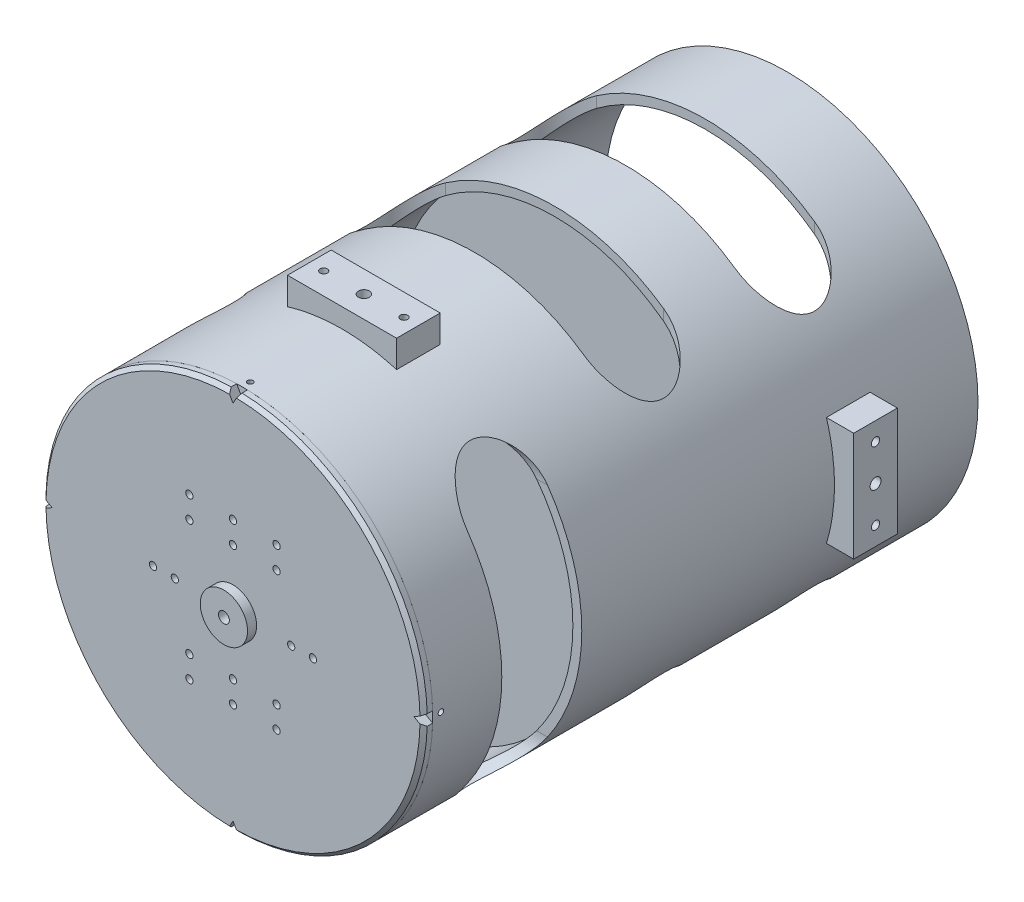
from build123d import *

# Parameters (mm, degrees)
ESQUISSE1_R                  = 104.9
ESQUISSE1_R_2                = 100
BOSS_EXTRU_1_DEPTH           = 300
ESQUISSE2_R                  = 100
BOSS_EXTRU_2_DEPTH           = 24
ESQUISSE3_R                  = 13
ENL_V_MAT_EXTRU_1_DEPTH      = 8
ESQUISSE5_R                  = 5
ENL_V_MAT_EXTRU_2_DEPTH      = 16
ESQUISSE6_R                  = 99.5
ESQUISSE6_R_2                = 95
BOSS_EXTRU_3_DEPTH           = 8
ESQUISSE7_R                  = 104.9
ESQUISSE7_R_2                = 3
BOSS_EXTRU_4_DEPTH           = 5
CHANFREIN1_SIZE              = 2
ESQUISSE8_R                  = 13
ESQUISSE8_R_2                = 3
BOSS_EXTRU_5_DEPTH           = 5
ENL_V_MAT_EXTRU_3_DEPTH      = 177.5
ESQUISSE10_R                 = 3
ENL_V_MAT_EXTRU_4_DEPTH      = 355
ENL_V_MAT_EXTRU_5_DEPTH      = 177.5
ESQUISSE12_W                 = 24
ESQUISSE12_H                 = 96
BOSS_EXTRU_6_DEPTH           = 12
ESQUISSE13_R                 = 2.25
ENL_V_MAT_EXTRU_6_DEPTH      = 25
ESQUISSE14_R                 = 2
ENL_V_MAT_EXTRU_7_DEPTH      = 25
ESQUISSE15_R                 = 3
ENL_V_MAT_EXTRU_8_DEPTH      = 147.5
ESQUISSE16_W                 = 96
ESQUISSE16_H                 = 24
BOSS_EXTRU_7_DEPTH           = 12
ESQUISSE17_R                 = 2.25
ENL_V_MAT_EXTRU_9_DEPTH      = 25
BOSS_EXTRU_8_DEPTH           = 12
BOSS_EXTRU_8_2_DEPTH         = 12
BOSS_EXTRU_9_DEPTH           = 12
BOSS_EXTRU_9_2_DEPTH         = 12
BOSS_EXTRU_10_DEPTH          = 12
ESQUISSE22_R                 = 2
ENL_V_MAT_EXTRU_10_DEPTH     = 17
SYM_TRIE7_COPY_1_SKETCH_R    = 2
SYM_TRIE7_COPY_1_DEPTH       = 17
ENL_V_MAT_EXTRU_11_REACH     = 222.419
ESQUISSE24_R                 = 3
BOSS_EXTRU_11_DEPTH          = 12
ESQUISSE27_R                 = 2.25
ENL_V_MAT_EXTRU_12_DEPTH     = 17
ESQUISSE28_R                 = 3
ENL_V_MAT_EXTRU_13_DEPTH     = 34
ESQUISSE29_R                 = 1.5
ENL_V_MAT_EXTRU_14_DEPTH     = 14
R_P_TITION_CIRCULAIRE1_COUNT = 4
ESQUISSE31_R                 = 2
ENL_V_MAT_EXTRU_15_DEPTH     = 5
ENL_V_MAT_EXTRU_16_DEPTH     = 14
ESQUISSE33_W                 = 6
ESQUISSE33_H                 = 24
BOSS_EXTRU_12_DEPTH          = 47
BOSS_EXTRU_12_2_DEPTH        = 47
BOSS_EXTRU_12_3_DEPTH        = 47
BOSS_EXTRU_12_4_DEPTH        = 47


with BuildPart() as part:
    # Esquisse1 → Boss.-Extru.1 (new body)
    with BuildSketch(Plane.XY):
        Circle(ESQUISSE1_R)
        Circle(ESQUISSE1_R_2, mode=Mode.SUBTRACT)
    extrude(amount=BOSS_EXTRU_1_DEPTH)

    # Esquisse9 → Enl_v. mat.-Extru.3 (cut, symmetric)
    with BuildSketch(Plane(origin=(0, 0, 0), x_dir=(1, 0, 0), z_dir=(0, 1, 0))):
        with BuildLine():
            Line((-60, -128), (60, -128))
            ThreePointArc((60, -128), (82, -150), (60, -172))
            Line((60, -172), (-60, -172))
            ThreePointArc((-60, -172), (-82, -150), (-60, -128))
        make_face()
    enl_v_mat_extru_3 = extrude(amount=ENL_V_MAT_EXTRU_3_DEPTH, both=True, mode=Mode.SUBTRACT)

    # Esquisse10 → Enl_v. mat.-Extru.4 (cut)
    with BuildSketch(Plane(origin=(0, -104.9, 0), x_dir=(1, 0, 0), z_dir=(0, 1, 0))):
        with Locations(Location((0, -233, 0), (0, 0, 90))):  # turned: the seam where the file's is
            Circle(ESQUISSE10_R)
    extrude(amount=ENL_V_MAT_EXTRU_4_DEPTH, mode=Mode.SUBTRACT)

    # Esquisse11 → Enl_v. mat.-Extru.5 (cut, symmetric)
    with BuildSketch(Plane.ZY):
        with BuildLine():
            Line((218, -60), (218, 60))
            ThreePointArc((218, 60), (240, 82), (262, 60))
            Line((262, 60), (262, -60))
            ThreePointArc((262, -60), (240, -82), (218, -60))
        make_face()
    extrude(amount=ENL_V_MAT_EXTRU_5_DEPTH, both=True, mode=Mode.SUBTRACT)

    # Esquisse15 → Enl_v. mat.-Extru.8 (cut, symmetric)
    with BuildSketch(Plane.ZY):
        with Locations((67, 0)):
            Circle(ESQUISSE15_R)
    extrude(amount=ENL_V_MAT_EXTRU_8_DEPTH, both=True, mode=Mode.SUBTRACT)

    # Sym_trie3: Enl_v. mat.-Extru.3 across plane
    add(enl_v_mat_extru_3.mirror(Plane.XY.offset(108.5)), mode=Mode.SUBTRACT)


with BuildPart() as body_2:
    # Esquisse2 → Boss.-Extru.2 (new body)
    with BuildSketch(Plane.XY.offset(210)):
        Circle(ESQUISSE2_R)
    extrude(amount=-BOSS_EXTRU_2_DEPTH)

    # Esquisse3 → Enl_v. mat.-Extru.1 (cut)
    with BuildSketch(Plane.XY.offset(210)):
        Circle(ESQUISSE3_R)
    extrude(amount=-ENL_V_MAT_EXTRU_1_DEPTH, mode=Mode.SUBTRACT)

    # Esquisse5 → Enl_v. mat.-Extru.2 (cut)
    with BuildSketch(Plane.XY.offset(202)):
        Circle(ESQUISSE5_R)
    extrude(amount=-ENL_V_MAT_EXTRU_2_DEPTH, mode=Mode.SUBTRACT)


with BuildPart() as body_3:
    # Sym_trie1: mirrored copy
    add(body_2.part.mirror(Plane.XY.offset(150)))


with BuildPart() as body_4:
    # Esquisse6 → Boss.-Extru.3 (new body)
    with BuildSketch(Plane.XY.offset(300)):
        Circle(ESQUISSE6_R)
        Circle(ESQUISSE6_R_2, mode=Mode.SUBTRACT)
    extrude(amount=-BOSS_EXTRU_3_DEPTH)

    # Esquisse7 → Boss.-Extru.4 (add)
    with BuildSketch(Plane.XY.offset(300)):
        Circle(ESQUISSE7_R)
        Circle(ESQUISSE7_R_2, mode=Mode.SUBTRACT)
    extrude(amount=BOSS_EXTRU_4_DEPTH)

    # Chanfrein1
    chanfrein1_edges = [body_4.edges().sort_by_distance(p)[0] for p in [
        (-104.9, 0, 305),
    ]]
    chamfer(chanfrein1_edges, length=CHANFREIN1_SIZE)

    # Esquisse14 → Enl_v. mat.-Extru.7 (cut)
    with BuildSketch(Plane.XY.offset(305)):
        with Locations((0, 32)):
            Circle(ESQUISSE14_R)
        with Locations((0, -32)):
            Circle(ESQUISSE14_R)
        with Locations((32, 0)):
            Circle(ESQUISSE14_R)
        with Locations((-32, 0)):
            Circle(ESQUISSE14_R)
        with Locations((0, 44)):
            Circle(ESQUISSE14_R)
        with Locations((44, 0)):
            Circle(ESQUISSE14_R)
        with Locations((0, -44)):
            Circle(ESQUISSE14_R)
        with Locations((-44, 0)):
            Circle(ESQUISSE14_R)
    extrude(amount=-ENL_V_MAT_EXTRU_7_DEPTH, mode=Mode.SUBTRACT)


with BuildPart() as body_5:
    # Esquisse8 → Boss.-Extru.5 (new body)
    with BuildSketch(Plane.XY.offset(305)):
        Circle(ESQUISSE8_R)
        Circle(ESQUISSE8_R_2, mode=Mode.SUBTRACT)
    extrude(amount=BOSS_EXTRU_5_DEPTH)


with BuildPart() as body_6:
    # Esquisse12 → Boss.-Extru.6 (new body, symmetric)
    with BuildSketch(Plane.XY.offset(233)):
        Rectangle(ESQUISSE12_W, ESQUISSE12_H)
    extrude(amount=BOSS_EXTRU_6_DEPTH, both=True)

    # Esquisse13 → Enl_v. mat.-Extru.6 (cut)
    with BuildSketch(Plane(origin=(0, 48, 0), x_dir=(0, 0, -1), z_dir=(0, 1, 0))):
        with Locations(Location((-233, 0, 0), (0, 0, 90))):  # turned: the seam where the file's is
            Circle(ESQUISSE13_R)
    enl_v_mat_extru_6 = extrude(amount=-ENL_V_MAT_EXTRU_6_DEPTH, mode=Mode.SUBTRACT)

    # Sym_trie2: Enl_v. mat.-Extru.6 across plane
    add(enl_v_mat_extru_6.mirror(Plane.ZX), mode=Mode.SUBTRACT)


with BuildPart() as body_7:
    # Esquisse16 → Boss.-Extru.7 (new body, symmetric)
    with BuildSketch(Plane.XY.offset(67)):
        Rectangle(ESQUISSE16_W, ESQUISSE16_H)
    extrude(amount=BOSS_EXTRU_7_DEPTH, both=True)

    # Esquisse17 → Enl_v. mat.-Extru.9 (cut)
    with BuildSketch(Plane.YZ.offset(48)):
        with Locations((0, 67)):
            Circle(ESQUISSE17_R)
    enl_v_mat_extru_9 = extrude(amount=-ENL_V_MAT_EXTRU_9_DEPTH, mode=Mode.SUBTRACT)

    # Sym_trie4: Enl_v. mat.-Extru.9 across plane
    add(enl_v_mat_extru_9.mirror(Plane.ZY), mode=Mode.SUBTRACT)


with BuildPart() as body_8:
    # Esquisse18 → Boss.-Extru.8 (new body, symmetric)
    with BuildSketch(Plane.XY.offset(233)):
        with BuildLine():
            Line((-12.5, 99.215674165), (-12.5, 84.215674165))
            Line((-12.5, 84.215674165), (12.5, 84.215674165))
            Line((12.5, 84.215674165), (12.5, 99.215674165))
            ThreePointArc((12.5, 99.215674165), (0, 100), (-12.5, 99.215674165))
        make_face()
    extrude(amount=BOSS_EXTRU_8_DEPTH, both=True)


with BuildPart() as body_9:
    # Esquisse18 → Boss.-Extru.8 2 (new body, symmetric)
    with BuildSketch(Plane.XY.offset(233)):
        with BuildLine():
            Line((12.5, -84.215674165), (12.5, -99.215674165))
            ThreePointArc((12.5, -99.215674165), (0, -100), (-12.5, -99.215674165))
            Line((-12.5, -99.215674165), (-12.5, -84.215674165))
            Line((-12.5, -84.215674165), (12.5, -84.215674165))
        make_face()
    extrude(amount=BOSS_EXTRU_8_2_DEPTH, both=True)


with BuildPart() as body_10:
    # Esquisse19 → Boss.-Extru.9 (new body, symmetric)
    with BuildSketch(Plane.XY.offset(67)):
        with BuildLine():
            Line((99.215674165, 12.5), (84.215674165, 12.5))
            Line((84.215674165, 12.5), (84.215674165, -12.5))
            Line((84.215674165, -12.5), (99.215674165, -12.5))
            ThreePointArc((99.215674165, -12.5), (100, 0), (99.215674165, 12.5))
        make_face()
    extrude(amount=BOSS_EXTRU_9_DEPTH, both=True)


with BuildPart() as body_11:
    # Esquisse19 → Boss.-Extru.9 2 (new body, symmetric)
    with BuildSketch(Plane.XY.offset(67)):
        with BuildLine():
            Line((-99.215674165, -12.5), (-84.215674165, -12.5))
            Line((-84.215674165, -12.5), (-84.215674165, 12.5))
            Line((-84.215674165, 12.5), (-99.215674165, 12.5))
            ThreePointArc((-99.215674165, 12.5), (-100, 0), (-99.215674165, -12.5))
        make_face()
    extrude(amount=BOSS_EXTRU_9_2_DEPTH, both=True)


with BuildPart() as body_12:
    # Esquisse21 → Boss.-Extru.10 (new body, symmetric)
    with BuildSketch(Plane.XY.offset(233)):
        with BuildLine():
            Line((-30, 100.518704727), (-30, 115.518704727))
            Line((-30, 115.518704727), (30, 115.518704727))
            Line((30, 115.518704727), (30, 100.518704727))
            ThreePointArc((30, 100.518704727), (0, 104.9), (-30, 100.518704727))
        make_face()
    extrude(amount=BOSS_EXTRU_10_DEPTH, both=True)


with BuildPart() as enl_v_mat_extru_10_tool:
    # Esquisse22 → Enl_v. mat.-Extru.10 (new body, symmetric)
    with BuildSketch(Plane(origin=(-15, 102.709352364, 0), x_dir=(0.98950331, 0.144510206, 0), z_dir=(-0.144510206, 0.98950331, 0))):
        with Locations((-5.15912059, -233)):
            Circle(ESQUISSE22_R)
    enl_v_mat_extru_10 = extrude(amount=ENL_V_MAT_EXTRU_10_DEPTH, both=True)


with BuildPart() as part_1:
    add(part.part)

    # Enl_v. mat.-Extru.10: cut by enl_v_mat_extru_10_tool
    add(enl_v_mat_extru_10_tool.part, mode=Mode.SUBTRACT)


with BuildPart() as body_12_1:
    add(body_12.part)

    # Enl_v. mat.-Extru.10: cut by enl_v_mat_extru_10_tool
    add(enl_v_mat_extru_10_tool.part, mode=Mode.SUBTRACT)


with BuildPart() as sym_trie5_tool:
    # Sym_trie5: Enl_v. mat.-Extru.10 across plane
    add(enl_v_mat_extru_10.mirror(Plane.ZY))


with BuildPart() as part_2:
    add(part_1.part)

    # Sym_trie5: cut by sym_trie5_tool
    add(sym_trie5_tool.part, mode=Mode.SUBTRACT)

    # Sym_trie7: Enl_v. mat.-Extru.10 across plane
    add(enl_v_mat_extru_10.mirror(Plane.ZX), mode=Mode.SUBTRACT)

    # Sym_trie7 copy 1 sketch → Sym_trie7 copy 1 (cut, symmetric)
    with BuildSketch(Plane(origin=(15, -102.709352364, 0), x_dir=(-0.98950331, -0.144510206, 0), z_dir=(0.144510206, -0.98950331, 0))):
        with Locations((-5.15912059, -233)):
            Circle(SYM_TRIE7_COPY_1_SKETCH_R)
    extrude(amount=SYM_TRIE7_COPY_1_DEPTH, both=True, mode=Mode.SUBTRACT)


with BuildPart() as body_12_2:
    add(body_12_1.part)

    # Sym_trie5: cut by sym_trie5_tool
    add(sym_trie5_tool.part, mode=Mode.SUBTRACT)

    # Esquisse24 → Enl_v. mat.-Extru.11 (cut, up to next)
    with BuildSketch(Plane(origin=(0, 115.518704727, 0), x_dir=(1, 0, 0), z_dir=(0, 1, 0)), mode=Mode.PRIVATE) as enl_v_mat_extru_11_sk1:
        with Locations(Location((0, -233, 0), (0, 0, 270))):  # turned: the seam where the file's is
            Circle(ESQUISSE24_R)
    enl_v_mat_extru_11_tool1 = extrude(enl_v_mat_extru_11_sk1.sketch, amount=-ENL_V_MAT_EXTRU_11_REACH, mode=Mode.PRIVATE) & body_12_2.part
    add(enl_v_mat_extru_11_tool1.solids().sort_by_distance((0, 115.518705, 233))[0], mode=Mode.SUBTRACT)


with BuildPart() as body_13:
    # Sym_trie10: mirrored copy
    add(body_12_2.part.mirror(Plane.ZX))


with BuildPart() as body_14:
    # Esquisse25 → Boss.-Extru.11 (new body, symmetric)
    with BuildSketch(Plane.XY.offset(67)):
        with BuildLine():
            Line((100.518704727, -30), (115.518704727, -30))
            Line((115.518704727, -30), (115.518704727, 30))
            Line((115.518704727, 30), (100.518704727, 30))
            ThreePointArc((100.518704727, 30), (104.9, 0), (100.518704727, -30))
        make_face()
    extrude(amount=BOSS_EXTRU_11_DEPTH, both=True)


with BuildPart() as enl_v_mat_extru_12_tool:
    # Esquisse27 → Enl_v. mat.-Extru.12 (new body, symmetric)
    with BuildSketch(Plane(origin=(102.709352364, 15, 0), x_dir=(0, 0, -1), z_dir=(0.98950331, 0.144510206, 0))):
        with Locations(Location((-67, 2.991467503, 0), (0, 0, 90))):  # turned: the seam where the file's is
            Circle(ESQUISSE27_R)
    enl_v_mat_extru_12 = extrude(amount=ENL_V_MAT_EXTRU_12_DEPTH, both=True)


with BuildPart() as part_3:
    add(part_2.part)

    # Enl_v. mat.-Extru.12: cut by enl_v_mat_extru_12_tool
    add(enl_v_mat_extru_12_tool.part, mode=Mode.SUBTRACT)


with BuildPart() as body_14_1:
    add(body_14.part)

    # Enl_v. mat.-Extru.12: cut by enl_v_mat_extru_12_tool
    add(enl_v_mat_extru_12_tool.part, mode=Mode.SUBTRACT)


with BuildPart() as sym_trie11_tool:
    # Sym_trie11: Enl_v. mat.-Extru.12 across plane
    add(enl_v_mat_extru_12.mirror(Plane.ZX))


with BuildPart() as part_4:
    add(part_3.part)

    # Sym_trie11: cut by sym_trie11_tool
    add(sym_trie11_tool.part, mode=Mode.SUBTRACT)


with BuildPart() as body_14_2:
    add(body_14_1.part)

    # Sym_trie11: cut by sym_trie11_tool
    add(sym_trie11_tool.part, mode=Mode.SUBTRACT)


with BuildPart() as enl_v_mat_extru_13_tool:
    # Esquisse28 → Enl_v. mat.-Extru.13 (new body)
    with BuildSketch(Plane(origin=(115.518704727, 0, 0), x_dir=(0, 0, -1), z_dir=(1, 0, 0))):
        with Locations(Location((-67, 0, 0), (0, 0, 90))):  # turned: the seam where the file's is
            Circle(ESQUISSE28_R)
    extrude(amount=-ENL_V_MAT_EXTRU_13_DEPTH)


with BuildPart() as body_10_1:
    add(body_10.part)

    # Enl_v. mat.-Extru.13: cut by enl_v_mat_extru_13_tool
    add(enl_v_mat_extru_13_tool.part, mode=Mode.SUBTRACT)


with BuildPart() as body_14_3:
    add(body_14_2.part)

    # Enl_v. mat.-Extru.13: cut by enl_v_mat_extru_13_tool
    add(enl_v_mat_extru_13_tool.part, mode=Mode.SUBTRACT)


with BuildPart() as body_15:
    # Sym_trie12: mirrored copy
    add(body_14_3.part.mirror(Plane.ZY))


with BuildPart() as enl_v_mat_extru_14_tool:
    # Esquisse29 → Enl_v. mat.-Extru.14 (new body)
    with BuildSketch(Plane(origin=(0, 104.9, 0), x_dir=(1, 0, 0), z_dir=(0, 1, 0))):
        with Locations(Location((0, -295.5, 0), (0, 0, 270))):  # turned: the seam where the file's is
            Circle(ESQUISSE29_R)
    enl_v_mat_extru_14 = extrude(amount=-ENL_V_MAT_EXTRU_14_DEPTH)


with BuildPart() as part_5:
    add(part_4.part)

    # Enl_v. mat.-Extru.14: cut by enl_v_mat_extru_14_tool
    add(enl_v_mat_extru_14_tool.part, mode=Mode.SUBTRACT)


with BuildPart() as body_4_1:
    add(body_4.part)

    # Enl_v. mat.-Extru.14: cut by enl_v_mat_extru_14_tool
    add(enl_v_mat_extru_14_tool.part, mode=Mode.SUBTRACT)


with BuildPart() as r_p_tition_circulaire1_tool:
    # R_p_tition circulaire1: Enl_v. mat.-Extru.14 ×4 about axis
    r_p_tition_circulaire1_axis = Axis((0, 0, 0), (0, 0, 1))
    for i in range(1, R_P_TITION_CIRCULAIRE1_COUNT):
        add(enl_v_mat_extru_14.rotate(r_p_tition_circulaire1_axis, i * 360 / R_P_TITION_CIRCULAIRE1_COUNT))


with BuildPart() as part_6:
    add(part_5.part)

    # R_p_tition circulaire1: cut by r_p_tition_circulaire1_tool
    add(r_p_tition_circulaire1_tool.part, mode=Mode.SUBTRACT)


with BuildPart() as body_4_2:
    add(body_4_1.part)

    # R_p_tition circulaire1: cut by r_p_tition_circulaire1_tool
    add(r_p_tition_circulaire1_tool.part, mode=Mode.SUBTRACT)

    # Esquisse31 → Enl_v. mat.-Extru.15 (cut)
    with BuildSketch(Plane(origin=(0, 0, 300), x_dir=(-1, 0, 0), z_dir=(0, 0, -1))):
        with Locations((-24, 44)):
            Circle(ESQUISSE31_R)
        with Locations((-24, 32)):
            Circle(ESQUISSE31_R)
        with Locations((24, 44)):
            Circle(ESQUISSE31_R)
        with Locations((24, 32)):
            Circle(ESQUISSE31_R)
        with Locations(Location((24, -32, 0), (0, 0, 180))):  # turned: the seam where the file's is
            Circle(ESQUISSE31_R)
        with Locations(Location((24, -44, 0), (0, 0, 180))):  # turned: the seam where the file's is
            Circle(ESQUISSE31_R)
        with Locations(Location((-24, -32, 0), (0, 0, 180))):  # turned: the seam where the file's is
            Circle(ESQUISSE31_R)
        with Locations(Location((-24, -44, 0), (0, 0, 180))):  # turned: the seam where the file's is
            Circle(ESQUISSE31_R)
    extrude(amount=-ENL_V_MAT_EXTRU_15_DEPTH, mode=Mode.SUBTRACT)

    # Esquisse32 → Enl_v. mat.-Extru.16 (cut)
    with BuildSketch(Plane(origin=(0, 0, 300), x_dir=(-1, 0, 0), z_dir=(0, 0, -1))):
        with BuildLine():
            Line((0, 99.5), (-3, 104.9))
            ThreePointArc((-3, 104.9), (-0.002982844, 105.366766432), (2.994034311, 104.9))
            Line((2.994034311, 104.9), (0, 99.5))
        make_face()
        with BuildLine():
            Line((99.5, 0), (104.9, 3))
            ThreePointArc((104.9, 3), (105.366766432, 0.002982844), (104.9, -2.994034311))
            Line((104.9, -2.994034311), (99.5, 0))
        make_face()
        with BuildLine():
            Line((0, -99.5), (3, -104.9))
            ThreePointArc((3, -104.9), (0.002982844, -105.366766432), (-2.994034311, -104.9))
            Line((-2.994034311, -104.9), (0, -99.5))
        make_face()
        with BuildLine():
            Line((-99.5, 0), (-104.9, -3))
            ThreePointArc((-104.9, -3), (-105.366766432, -0.002982844), (-104.9, 2.994034311))
            Line((-104.9, 2.994034311), (-99.5, 0))
        make_face()
    extrude(amount=-ENL_V_MAT_EXTRU_16_DEPTH, mode=Mode.SUBTRACT)


with BuildPart() as body_16:
    # Esquisse33 → Boss.-Extru.12 (new body)
    with BuildSketch(Plane(origin=(0, 0, 300), x_dir=(-1, 0, 0), z_dir=(0, 0, -1))):
        with Locations((-24, 38)):
            Rectangle(ESQUISSE33_W, ESQUISSE33_H)
    extrude(amount=BOSS_EXTRU_12_DEPTH)


with BuildPart() as body_17:
    # Esquisse33 → Boss.-Extru.12 2 (new body)
    with BuildSketch(Plane(origin=(0, 0, 300), x_dir=(-1, 0, 0), z_dir=(0, 0, -1))):
        with Locations((24, 38)):
            Rectangle(ESQUISSE33_W, ESQUISSE33_H)
    extrude(amount=BOSS_EXTRU_12_2_DEPTH)


with BuildPart() as body_18:
    # Esquisse33 → Boss.-Extru.12 3 (new body)
    with BuildSketch(Plane(origin=(0, 0, 300), x_dir=(-1, 0, 0), z_dir=(0, 0, -1))):
        with Locations((24, -38)):
            Rectangle(ESQUISSE33_W, ESQUISSE33_H)
    extrude(amount=BOSS_EXTRU_12_3_DEPTH)


with BuildPart() as body_19:
    # Esquisse33 → Boss.-Extru.12 4 (new body)
    with BuildSketch(Plane(origin=(0, 0, 300), x_dir=(-1, 0, 0), z_dir=(0, 0, -1))):
        with Locations((-24, -38)):
            Rectangle(ESQUISSE33_W, ESQUISSE33_H)
    extrude(amount=BOSS_EXTRU_12_4_DEPTH)


solid = Compound([body_2.part, body_3.part, body_5.part, body_6.part, body_7.part, body_8.part, body_9.part, body_11.part, body_12_2.part, body_13.part, body_10_1.part, body_14_3.part, body_15.part, part_6.part, body_4_2.part, body_16.part, body_17.part, body_18.part, body_19.part])
